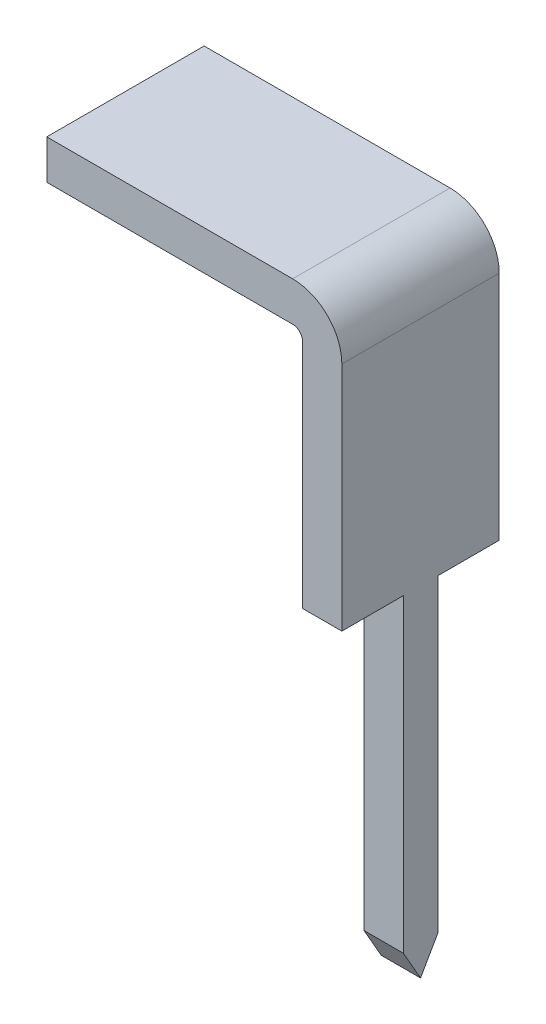
from build123d import *

# Parameters (mm, degrees)
BOSS_EXTRUDE1_DEPTH = 1.6
SKETCH2_W           = 0.625
SKETCH2_H           = 3.5
CUT_EXTRUDE1_DEPTH  = 1.6
BOSS_EXTRUDE2_DEPTH = 0.4


with BuildPart() as part:
    # Sketch1 → Boss-Extrude1 (new body)
    with BuildSketch(Plane.XY):
        with BuildLine():
            Line((0, 0), (0, 5.5))
            ThreePointArc((0, 5.5), (-0.146446609, 5.853553391), (-0.5, 6))
            Line((-0.5, 6), (-3, 6))
            Line((-3, 6), (-3, 5.6))
            Line((-3, 5.6), (-0.5, 5.6))
            ThreePointArc((-0.5, 5.6), (-0.429289322, 5.570710678), (-0.4, 5.5))
            Line((-0.4, 5.5), (-0.4, 0))
            Line((-0.4, 0), (0, 0))
        make_face()
    extrude(amount=BOSS_EXTRUDE1_DEPTH)

    # Sketch2 → Cut-Extrude1 (cut)
    with BuildSketch(Plane(origin=(0, 0, 0), x_dir=(0, 0, -1), z_dir=(1, 0, 0))):
        with Locations((-1.2875, 1.398103513)):
            Rectangle(SKETCH2_W, SKETCH2_H)
        with Locations((-0.3125, 1.398103513)):
            Rectangle(SKETCH2_W, SKETCH2_H)
    extrude(amount=-CUT_EXTRUDE1_DEPTH, mode=Mode.SUBTRACT)

    # Sketch3 → Boss-Extrude2 (add)
    with BuildSketch(Plane(origin=(0, 0, 0), x_dir=(0, 0, -1), z_dir=(1, 0, 0))):
        Polygon((-0.975, 0), (-0.8, -0.305627674), (-0.625, 0), align=None)
    extrude(amount=-BOSS_EXTRUDE2_DEPTH)


solid = part.part
